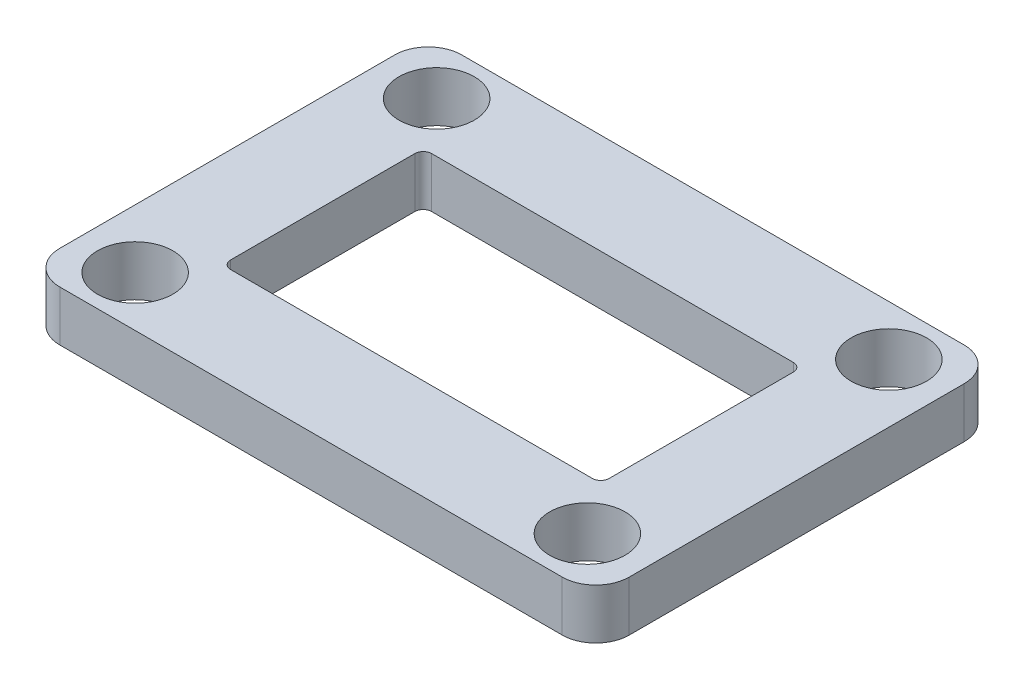
from build123d import *

# Parameters (mm, degrees)
SKETCH1_W           = 34
SKETCH1_H           = 24
SKETCH1_R           = 2.25
SKETCH1_W_2         = 22.6
SKETCH1_H_2         = 12
BOSS_EXTRUDE1_DEPTH = 3
FILLET1_R           = 0.5
FILLET2_R           = 2


with BuildPart() as part:
    # Sketch1 → Boss-Extrude1 (new body)
    with BuildSketch(Plane(origin=(0, 0, 0), x_dir=(1, 0, 0), z_dir=(0, 1, 0))):
        Rectangle(SKETCH1_W, SKETCH1_H)
        with Locations((-13.5, -9)):
            Circle(SKETCH1_R, mode=Mode.SUBTRACT)
        with Locations((-13.5, 9)):
            Circle(SKETCH1_R, mode=Mode.SUBTRACT)
        with Locations((13.5, -9)):
            Circle(SKETCH1_R, mode=Mode.SUBTRACT)
        with Locations((13.5, 9)):
            Circle(SKETCH1_R, mode=Mode.SUBTRACT)
        Rectangle(SKETCH1_W_2, SKETCH1_H_2, mode=Mode.SUBTRACT)
    extrude(amount=BOSS_EXTRUDE1_DEPTH)

    # Fillet1
    fillet1_edges = [part.edges().sort_by_distance(p)[0] for p in [
        (11.3, 1.5, 6),
        (11.3, 1.5, -6),
        (-11.3, 1.5, -6),
        (-11.3, 1.5, 6),
    ]]
    fillet(fillet1_edges, radius=FILLET1_R)

    # Fillet2
    fillet2_edges = [part.edges().sort_by_distance(p)[0] for p in [
        (17, 1.5, 12),
        (-17, 1.5, 12),
        (-17, 1.5, -12),
        (17, 1.5, -12),
    ]]
    fillet(fillet2_edges, radius=FILLET2_R)


solid = part.part
